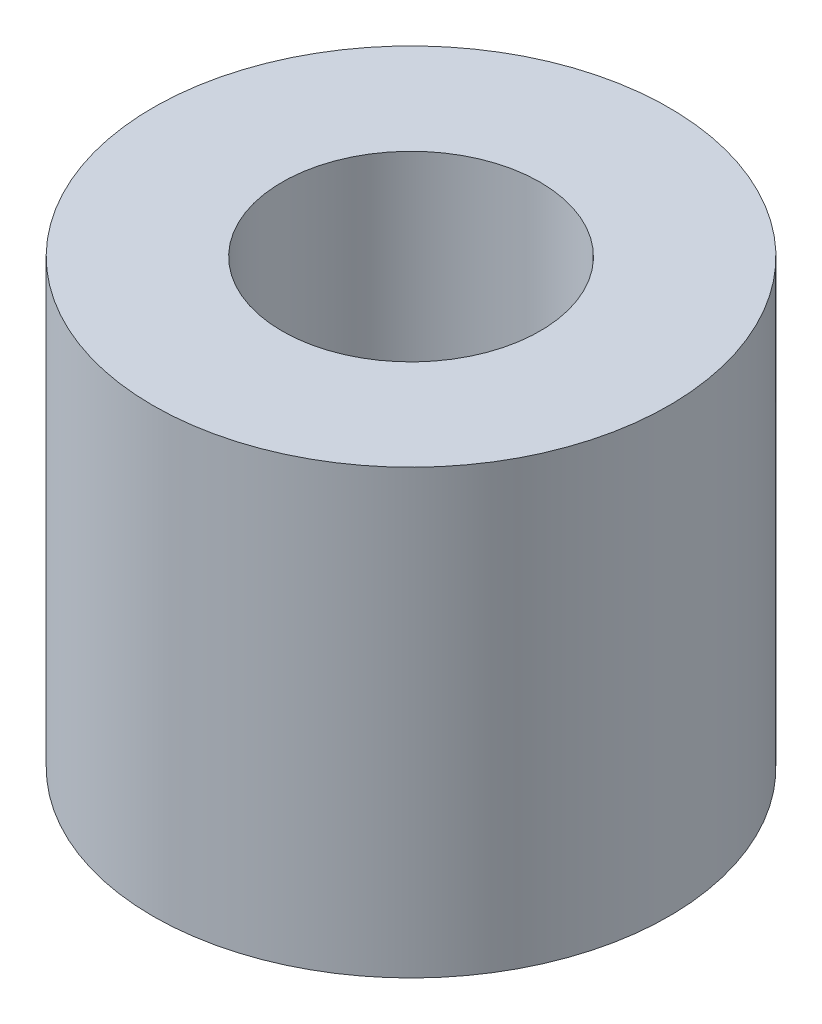
from build123d import *

# Parameters (mm, degrees)
SKETCH1_R           = 3.5
SKETCH1_R_2         = 1.75
BOSS_EXTRUDE1_DEPTH = 6


with BuildPart() as part:
    # Sketch1 → Boss-Extrude1 (new body)
    with BuildSketch(Plane(origin=(0, 0, 0), x_dir=(1, 0, 0), z_dir=(0, 1, 0))):
        Circle(SKETCH1_R)
        Circle(SKETCH1_R_2, mode=Mode.SUBTRACT)
    extrude(amount=BOSS_EXTRUDE1_DEPTH)


solid = part.part
